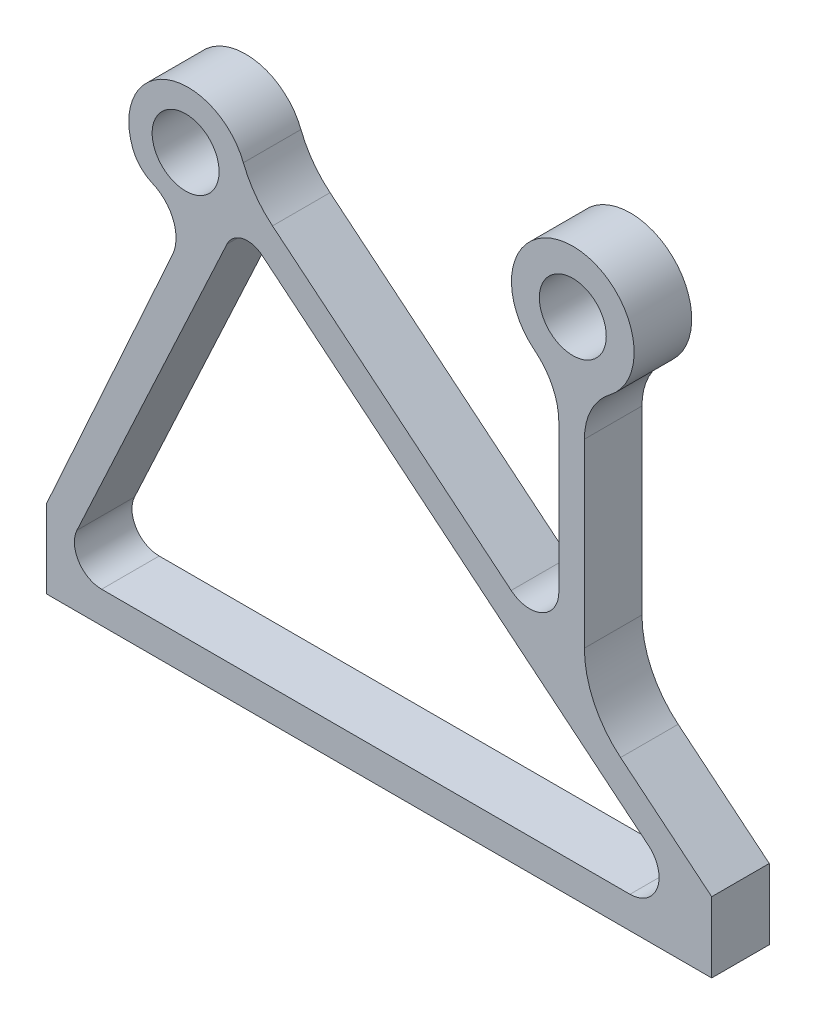
from build123d import *

# Parameters (mm, degrees)
SZKIC2_R                    = 23.25
DODANIE_WYCI_GNI_CIE2_DEPTH = 40


with BuildPart() as part:
    # Szkic2 → Dodanie-wyciągnięcie2 (new body)
    with BuildSketch(Plane.XY):
        with BuildLine():
            Line((0, 0), (0, 54.688934957))
            Line((0, 54.688934957), (87.453362302, 248.067468892))
            ThreePointArc((87.453362302, 248.067468892), (87.993040755, 268.91551183), (73.44838199, 283.861583171))
            ThreePointArc((73.44838199, 283.861583171), (65.201876961, 289.507605405), (59.808019866, 297.921208552))
            ThreePointArc((59.808019866, 297.921208552), (83.279468744, 351.232430567), (136.626207071, 327.841816741))
            ThreePointArc((136.626207071, 327.841816741), (144.956248443, 312.604323506), (156.856823864, 299.957304331))
            Line((156.856823864, 299.957304331), (322.684534721, 163.527324946))
            ThreePointArc((322.684534721, 163.527324946), (344.192875478, 160.854554943), (355.793873119, 179.162183827))
            Line((355.793873119, 179.162183827), (355.793873119, 281.253729426))
            ThreePointArc((355.793873119, 281.253729426), (351.366678921, 300.628861995), (338.963821807, 316.158348333))
            ThreePointArc((338.963821807, 316.158348333), (366.011924038, 392.109534411), (391.227480575, 315.530436679))
            ThreePointArc((391.227480575, 315.530436679), (378.213678028, 299.824941516), (373.550822068, 279.968471302))
            Line((373.550822068, 279.968471302), (373.550822068, 154.228140368))
            ThreePointArc((373.550822068, 154.228140368), (380.150790995, 124.795180873), (398.686800685, 100.998646686))
            Line((398.686800685, 100.998646686), (462, 48.909533035))
            Line((462, 48.909533035), (462, 0))
            Line((462, 0), (0, 0))
        make_face()
        with Locations((96.5, 314)):
            Circle(SZKIC2_R, mode=Mode.SUBTRACT)
        with Locations((365.5, 349.5)):
            Circle(SZKIC2_R, mode=Mode.SUBTRACT)
        with BuildLine():
            Line((38.140490442, 21.985652154), (405.231641072, 21.985652154))
            ThreePointArc((405.231641072, 21.985652154), (424.253349591, 35.373578819), (418.06991605, 57.797385924))
            Line((418.06991605, 57.797385924), (149.573518435, 278.695074266))
            ThreePointArc((149.573518435, 278.695074266), (136.029024136, 281.900539629), (125.203881252, 273.151561656))
            Line((125.203881252, 273.151561656), (20.983248041, 48.87798069))
            ThreePointArc((20.983248041, 48.87798069), (22.19081724, 30.72910257), (38.140490442, 21.985652154))
        make_face(mode=Mode.SUBTRACT)
    extrude(amount=DODANIE_WYCI_GNI_CIE2_DEPTH)


solid = part.part
